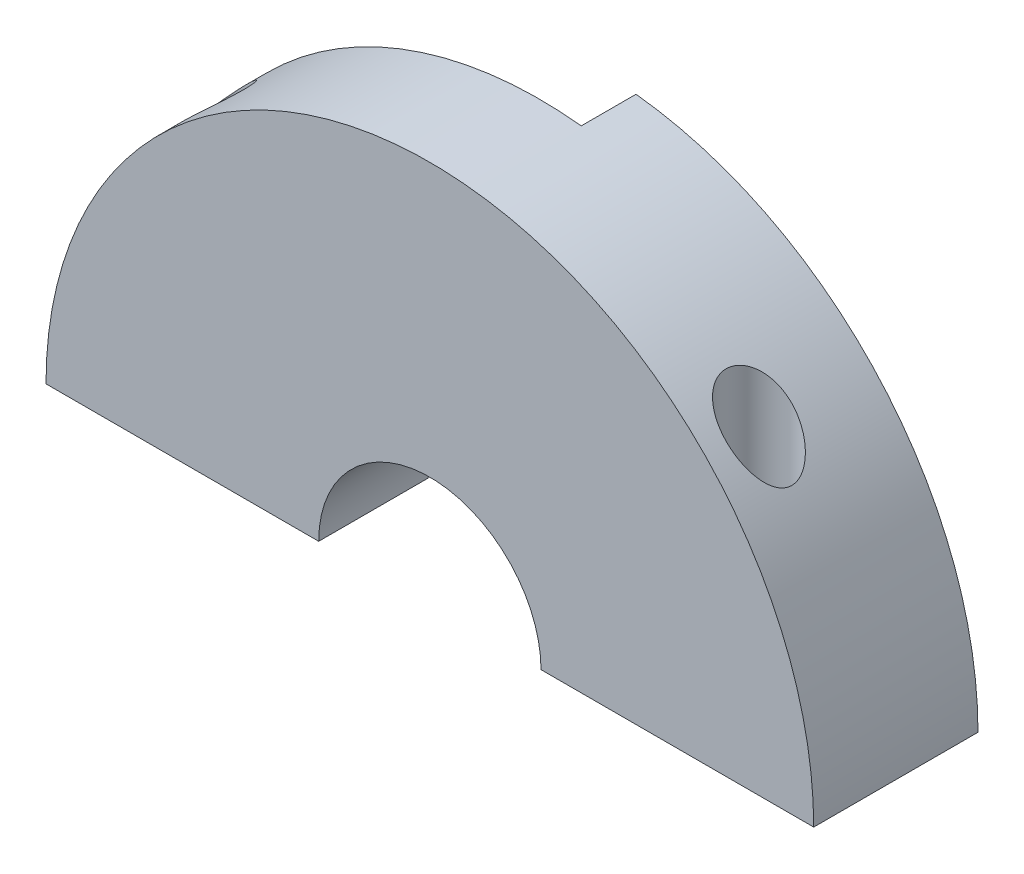
from build123d import *

# Parameters (mm, degrees)
BOSS_EXTRUDE1_DEPTH = 5
SKETCH2_R           = 1.7
CUT_EXTRUDE1_DEPTH  = 36.05
CUT_EXTRUDE2_START  = 2
SKETCH3_R           = 3
CUT_EXTRUDE2_DEPTH  = 34.0500001
BOSS_EXTRUDE2_DEPTH = 5
SKETCH5_W           = 3.825
SKETCH5_H           = 24.9
CUT_EXTRUDE3_DEPTH  = 6
SKETCH6_W           = 5
SKETCH6_H           = 34.840664101
CUT_EXTRUDE4_DEPTH  = 32.2250001


with BuildPart() as part:
    # Sketch1 → Boss-Extrude1 (new body, symmetric)
    with BuildSketch(Plane.XY):
        with BuildLine():
            Line((-35.05, 0), (-10.15, 0))
            ThreePointArc((-10.15, 0), (0, 10.15), (10.15, 0))
            Line((10.15, 0), (35.05, 0))
            ThreePointArc((35.05, 0), (0, 35.05), (-35.05, 0))
        make_face()
    extrude(amount=BOSS_EXTRUDE1_DEPTH, both=True)

    # Sketch2 → Cut-Extrude1 (cut, through all)
    with BuildSketch(Plane(origin=(0, 0, 0), x_dir=(1, 0, 0), z_dir=(0, 1, 0))):
        with Locations((-25.05, 0)):
            Circle(SKETCH2_R)
    cut_extrude1 = extrude(amount=CUT_EXTRUDE1_DEPTH, mode=Mode.SUBTRACT)

    # Sketch3 → Cut-Extrude2 (cut, through all)
    with BuildSketch(Plane(origin=(0, 0, 0), x_dir=(1, 0, 0), z_dir=(0, 1, 0)).offset(CUT_EXTRUDE2_START)):
        with Locations((-25.05, 0)):
            Circle(SKETCH3_R)
    cut_extrude2 = extrude(amount=CUT_EXTRUDE2_DEPTH, mode=Mode.SUBTRACT)

    # Mirror1: Cut-Extrude1, Cut-Extrude2 across plane
    add(cut_extrude1.mirror(Plane(origin=(0, 0, 0), x_dir=(0, 0, 1), z_dir=(1, 0, 0))), mode=Mode.SUBTRACT)
    add(cut_extrude2.mirror(Plane(origin=(0, 0, 0), x_dir=(0, 0, 1), z_dir=(1, 0, 0))), mode=Mode.SUBTRACT)

    # Sketch4 → Boss-Extrude2 (add)
    with BuildSketch(Plane.XY.offset(5)):
        with BuildLine():
            Line((0, 12.5), (0, 35.05))
            ThreePointArc((0, 35.05), (24.784092681, 24.784092681), (35.05, 0))
            Line((35.05, 0), (12.5, 0))
            ThreePointArc((12.5, 0), (8.838834765, 8.838834765), (0, 12.5))
        make_face()
    boss_extrude2 = extrude(amount=BOSS_EXTRUDE2_DEPTH)

    # Sketch5 → Cut-Extrude3 (cut, through all)
    with BuildSketch(Plane.XY.offset(5)):
        with Locations((1.9125, 22.6)):
            Rectangle(SKETCH5_W, SKETCH5_H)
    cut_extrude3 = extrude(amount=CUT_EXTRUDE3_DEPTH, mode=Mode.SUBTRACT)

    # Mirror2: Boss-Extrude2, Cut-Extrude3 across plane
    add(boss_extrude2.mirror(Plane.XY))
    add(cut_extrude3.mirror(Plane.XY), mode=Mode.SUBTRACT)

    # Sketch6 → Cut-Extrude4 (cut, through all)
    with BuildSketch(Plane.ZY.offset(-3.825)):
        with Locations((7.5, 17.420332051)):
            Rectangle(SKETCH6_W, SKETCH6_H)
    extrude(amount=-CUT_EXTRUDE4_DEPTH, mode=Mode.SUBTRACT)


solid = part.part
